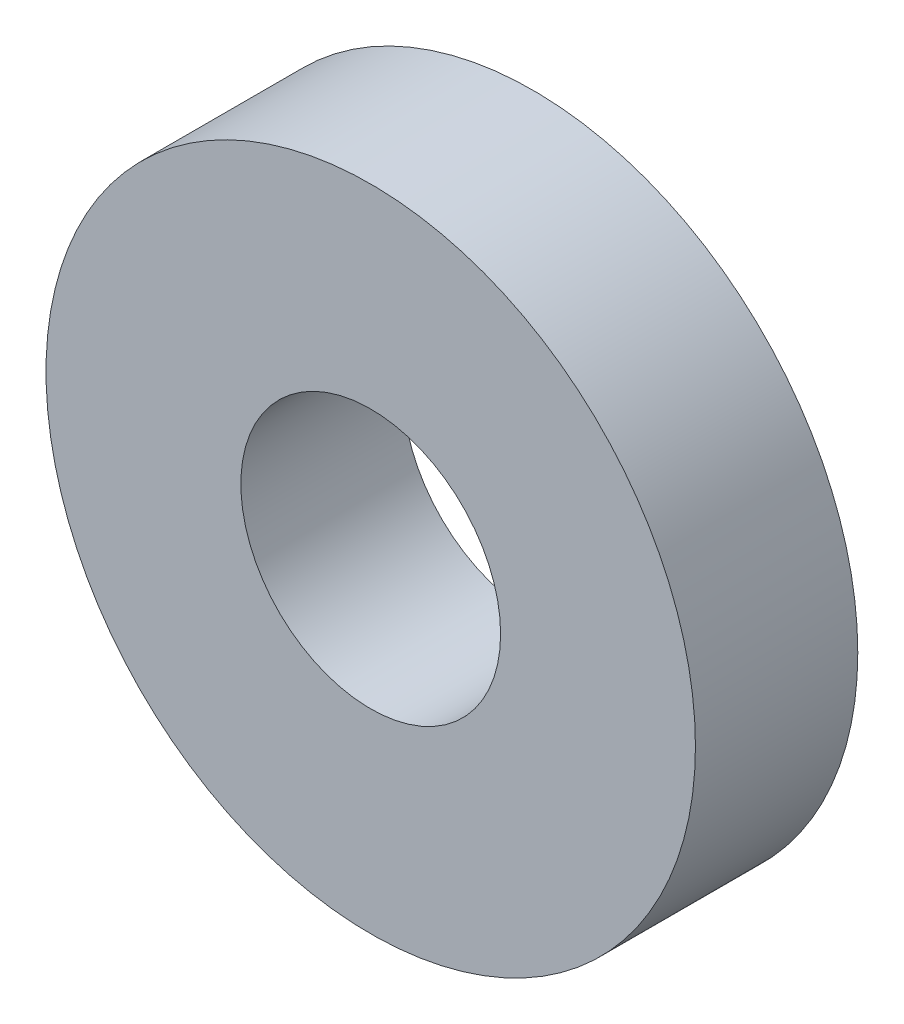
from build123d import *

# Parameters (mm, degrees)
SKETCH1_R           = 10
SKETCH1_R_2         = 4
BOSS_EXTRUDE1_DEPTH = 5


with BuildPart() as part:
    # Sketch1 → Boss-Extrude1 (new body)
    with BuildSketch(Plane.XY):
        Circle(SKETCH1_R)
        Circle(SKETCH1_R_2, mode=Mode.SUBTRACT)
    extrude(amount=BOSS_EXTRUDE1_DEPTH)


solid = part.part
